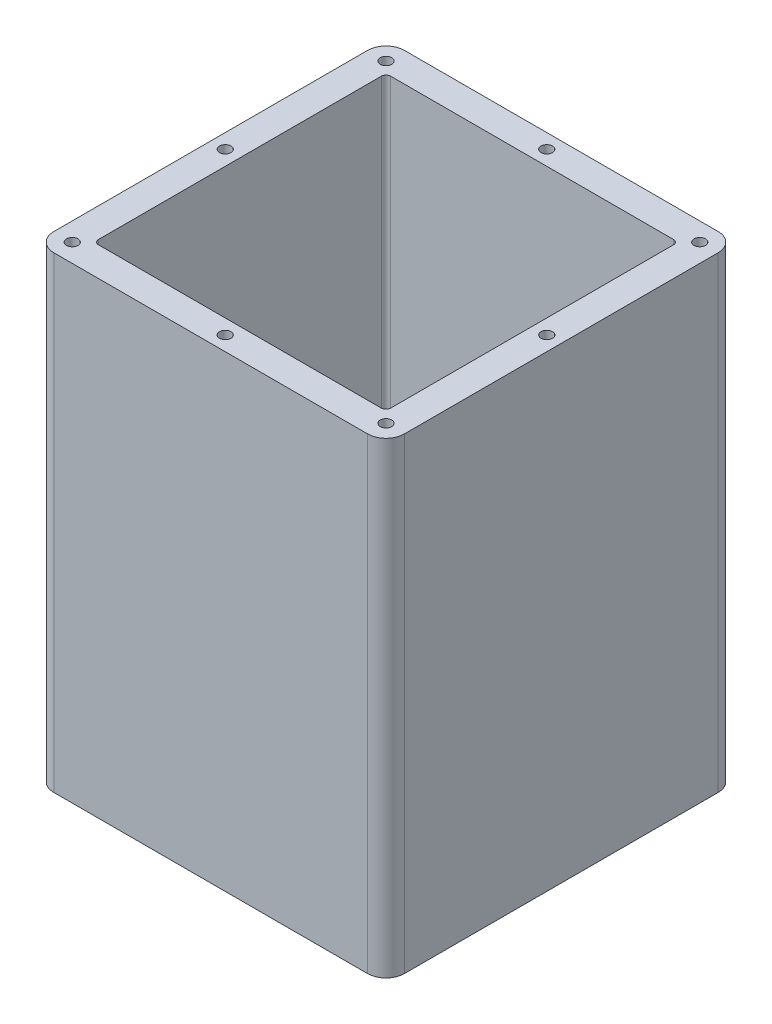
from build123d import *

# Parameters (mm, degrees)
BOSS_EXTRUDE1_DEPTH       = 101.603999992
CUT_EXTRUDE1_DEPTH        = 246.126
SKETCH14_W                = 76.2
SKETCH14_H                = 76.2
SKETCH14_W_2              = 63.5
SKETCH14_H_2              = 63.5
BOSS_EXTRUDE3_DEPTH       = 101.603999992
FILLET1_R                 = 4
M3X0_5_TAPPED_HOLE2_D     = 2.5
M3X0_5_TAPPED_HOLE2_DEPTH = 7.5
M3X0_5_TAPPED_HOLE2_TIP   = 0.751075774
M3X0_5_TAPPED_HOLE1_D     = 2.5
M3X0_5_TAPPED_HOLE1_DEPTH = 7.5
M3X0_5_TAPPED_HOLE1_TIP   = 0.751075774
FILLET2_R                 = 1


with BuildPart() as part:
    # Sketch1 → Boss-Extrude1 (new body)
    with BuildSketch(Plane(origin=(0, 0, 0), x_dir=(1, 0, 0), z_dir=(0, 1, 0))):
        with BuildLine():
            Line((-35.56, -38.1), (35.56, -38.1))
            ThreePointArc((35.56, -38.1), (37.356051224, -37.356051224), (38.1, -35.56))
            Line((38.1, -35.56), (38.1, 35.56))
            ThreePointArc((38.1, 35.56), (37.356051224, 37.356051224), (35.56, 38.1))
            Line((35.56, 38.1), (-35.56, 38.1))
            ThreePointArc((-35.56, 38.1), (-37.356051224, 37.356051224), (-38.1, 35.56))
            Line((-38.1, 35.56), (-38.1, -35.56))
            ThreePointArc((-38.1, -35.56), (-37.356051224, -37.356051224), (-35.56, -38.1))
        make_face()
    extrude(amount=BOSS_EXTRUDE1_DEPTH)

    # Sketch9 → Cut-Extrude1 (cut)
    with BuildSketch(Plane(origin=(0, 101.603999992, 0), x_dir=(1, 0, 0), z_dir=(0, 1, 0))):
        with BuildLine():
            Line((-30.56, -33.1), (30.56, -33.1))
            ThreePointArc((30.56, -33.1), (32.356051224, -32.356051224), (33.1, -30.56))
            Line((33.1, -30.56), (33.1, 30.56))
            ThreePointArc((33.1, 30.56), (32.356051224, 32.356051224), (30.56, 33.1))
            Line((30.56, 33.1), (-30.56, 33.1))
            ThreePointArc((-30.56, 33.1), (-32.356051224, 32.356051224), (-33.1, 30.56))
            Line((-33.1, 30.56), (-33.1, -30.56))
            ThreePointArc((-33.1, -30.56), (-32.356051224, -32.356051224), (-30.56, -33.1))
        make_face()
    extrude(amount=-CUT_EXTRUDE1_DEPTH, mode=Mode.SUBTRACT)

    # Sketch14 → Boss-Extrude3 (add)
    with BuildSketch(Plane(origin=(0, 101.603999992, 0), x_dir=(1, 0, 0), z_dir=(0, 1, 0))):
        Rectangle(SKETCH14_W, SKETCH14_H)
        Rectangle(SKETCH14_W_2, SKETCH14_H_2, mode=Mode.SUBTRACT)
    extrude(amount=-BOSS_EXTRUDE3_DEPTH)

    # Fillet1
    fillet1_edges = [part.edges().sort_by_distance(p)[0] for p in [
        (38.1, 50.801999996, -38.1),
        (38.1, 50.801999996, 38.1),
        (-38.1, 50.801999996, 38.1),
        (-38.1, 50.801999996, -38.1),
    ]]
    fillet(fillet1_edges, radius=FILLET1_R)

    # M3x0.5 Tapped Hole2
    with Locations(Plane(origin=(0, 101.603999992, 0), x_dir=(1, 0, 0), z_dir=(0, 1, 0))):
        with Locations((-34.1, 34.1), (34.1, 34.1), (34.1, -34.100008), (-34.1, -34.100008), (-34.95, 0), (34.94999995, 0), (0, -34.95), (0, 34.95)):
            Hole(M3X0_5_TAPPED_HOLE2_D / 2, depth=M3X0_5_TAPPED_HOLE2_DEPTH)
            with Locations((0, 0, -(M3X0_5_TAPPED_HOLE2_DEPTH + M3X0_5_TAPPED_HOLE2_TIP / 2))):  # 118° drill point
                Cone(0, M3X0_5_TAPPED_HOLE2_D / 2, M3X0_5_TAPPED_HOLE2_TIP, mode=Mode.SUBTRACT)

    # M3x0.5 Tapped Hole1
    with Locations(Plane(origin=(0, 0, 0), x_dir=(-1, 0, 0), z_dir=(0, -1, 0))):
        with Locations((-34.100008, 34.1), (34.1, 34.1), (34.1, -34.1), (-34.100008, -34.1), (-34.95, 0), (0, 34.95), (34.95, 0), (0, -34.94999995)):
            Hole(M3X0_5_TAPPED_HOLE1_D / 2, depth=M3X0_5_TAPPED_HOLE1_DEPTH)
            with Locations((0, 0, -(M3X0_5_TAPPED_HOLE1_DEPTH + M3X0_5_TAPPED_HOLE1_TIP / 2))):  # 118° drill point
                Cone(0, M3X0_5_TAPPED_HOLE1_D / 2, M3X0_5_TAPPED_HOLE1_TIP, mode=Mode.SUBTRACT)

    # Fillet2
    fillet2_edges = [part.edges().sort_by_distance(p)[0] for p in [
        (31.75, 50.801999996, 31.75),
        (-31.75, 50.801999996, 31.75),
        (-31.75, 50.801999996, -31.75),
        (31.75, 50.801999996, -31.75),
    ]]
    fillet(fillet2_edges, radius=FILLET2_R)


solid = part.part
